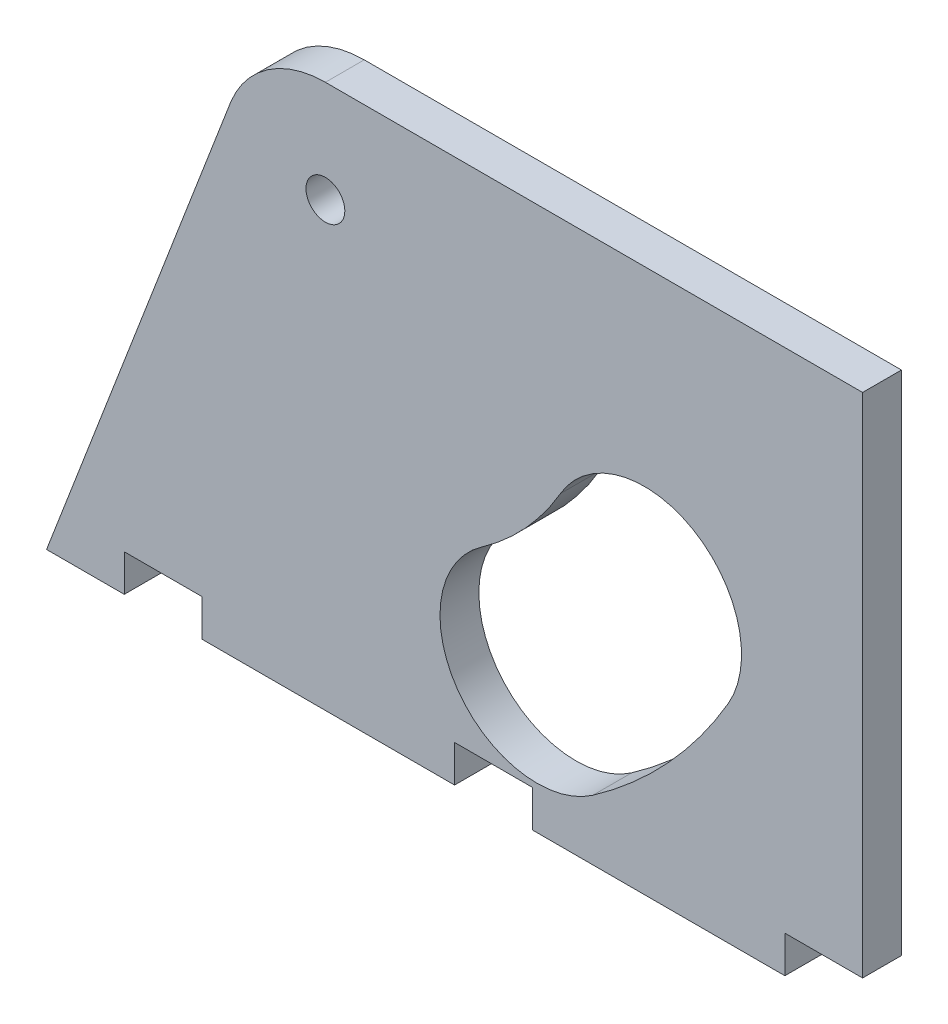
from build123d import *

# Parameters (mm, degrees)
SKETCH1_W           = 120
SKETCH1_H           = 100
BOSS_EXTRUDE1_DEPTH = 5
SKETCH2_R           = 2.5
CUT_EXTRUDE1_DEPTH  = 6
SKETCH3_W           = 120
SKETCH3_H           = 2
BOSS_EXTRUDE2_DEPTH = 20
CUT_EXTRUDE2_DEPTH  = 26
CUT_EXTRUDE3_DEPTH  = 26
SKETCH6_W           = 5
SKETCH6_H           = 30
BOSS_EXTRUDE3_DEPTH = 20
CUT_EXTRUDE4_DEPTH  = 106
SKETCH10_W          = 27.884556649
SKETCH10_H          = 70
CUT_EXTRUDE5_DEPTH  = 106
SKETCH11_W          = 20
SKETCH11_H          = 30
CUT_EXTRUDE6_DEPTH  = 106
SKETCH12_W          = 10
SKETCH12_H          = 4.75
CUT_EXTRUDE7_DEPTH  = 6


with BuildPart() as part:
    # Sketch1 → Boss-Extrude1 (new body)
    with BuildSketch(Plane.XY):
        with Locations((60, 50)):
            Rectangle(SKETCH1_W, SKETCH1_H)
    boss_extrude1 = extrude(amount=BOSS_EXTRUDE1_DEPTH)

    # Sketch2 → Cut-Extrude1 (cut, through all)
    with BuildSketch(Plane.XY.offset(5)):
        with Locations((50.878001036, 56.909722104)):
            Circle(SKETCH2_R)
        with BuildLine():
            ThreePointArc((85.292587217, 7.760599446), (95.03577446, 16.288409394), (102.722518982, 26.707967867))
            ThreePointArc((102.722518982, 26.707967867), (98.213609876, 43.800941239), (81.120636505, 39.292032133))
            ThreePointArc((81.120636505, 39.292032133), (76.6367022, 33.213956356), (70.953176308, 28.239400554))
            ThreePointArc((70.953176308, 28.239400554), (67.883481209, 10.830294546), (85.292587217, 7.760599446))
        make_face()
    cut_extrude1 = extrude(amount=-CUT_EXTRUDE1_DEPTH, mode=Mode.SUBTRACT)

    # Sketch3 → Boss-Extrude2 (add)
    with BuildSketch(Plane(origin=(0, 0, 0), x_dir=(-1, 0, 0), z_dir=(0, 0, -1))):
        with Locations((-60, 1)):
            Rectangle(SKETCH3_W, SKETCH3_H)
    boss_extrude2 = extrude(amount=BOSS_EXTRUDE2_DEPTH)

    # Sketch4 → Cut-Extrude2 (cut, through all)
    with BuildSketch(Plane.XY.offset(5)):
        with BuildLine():
            ThreePointArc((71.705399269, 35.987211382), (76.514173113, 43.433069144), (75.177144341, 52.195343835))
            ThreePointArc((75.177144341, 52.195343835), (71.771162127, 53.143650303), (70.822855659, 49.737668089))
            ThreePointArc((70.822855659, 49.737668089), (71.625072922, 44.480303275), (68.739808616, 40.012788618))
            ThreePointArc((68.739808616, 40.012788618), (68.209815325, 36.517204673), (71.705399269, 35.987211382))
        make_face()
    extrude(amount=-CUT_EXTRUDE2_DEPTH, mode=Mode.SUBTRACT)

    # Sketch5 → Cut-Extrude3 (cut, through all)
    with BuildSketch(Plane.XY.offset(5)):
        with BuildLine():
            Line((120, 70), (50.878001036, 70))
            ThreePointArc((50.878001036, 70), (43.464411706, 67.698330385), (38.657892056, 61.602728806))
            Line((38.657892056, 61.602728806), (15, 0))
            Line((15, 0), (0, 0))
            Line((0, 0), (0, 100))
            Line((0, 100), (120, 100))
            Line((120, 100), (120, 70))
        make_face()
    cut_extrude3 = extrude(amount=-CUT_EXTRUDE3_DEPTH, mode=Mode.SUBTRACT)

    # Sketch6 → Boss-Extrude3 (add, through all)
    with BuildSketch(Plane(origin=(0, 0, 0), x_dir=(-1, 0, 0), z_dir=(0, 0, -1))):
        with Locations((-117.5, 15)):
            Rectangle(SKETCH6_W, SKETCH6_H)
        with Locations((-32.5, 15)):
            Rectangle(SKETCH6_W, SKETCH6_H)
    boss_extrude3 = extrude(amount=BOSS_EXTRUDE3_DEPTH)

    # Sketch9 → Cut-Extrude4 (cut, through all)
    with BuildSketch(Plane(origin=(120, 0, 0), x_dir=(0, 0, -1), z_dir=(1, 0, 0))):
        Polygon((0, 30), (20, 0), (20, 30), align=None)
    cut_extrude4 = extrude(amount=-CUT_EXTRUDE4_DEPTH, mode=Mode.SUBTRACT)

    # Mirror1: Boss-Extrude1, Cut-Extrude1, Boss-Extrude2, Cut-Extrude3, Boss-Extrude3, Cut-Extrude4 across plane
    add(boss_extrude1.mirror(Plane(origin=(0, 0, 5), x_dir=(1, 0, 0), z_dir=(0, 0, -1))))
    add(cut_extrude1.mirror(Plane(origin=(0, 0, 5), x_dir=(1, 0, 0), z_dir=(0, 0, -1))), mode=Mode.SUBTRACT)
    add(boss_extrude2.mirror(Plane(origin=(0, 0, 5), x_dir=(1, 0, 0), z_dir=(0, 0, -1))))
    add(cut_extrude3.mirror(Plane(origin=(0, 0, 5), x_dir=(1, 0, 0), z_dir=(0, 0, -1))), mode=Mode.SUBTRACT)
    add(boss_extrude3.mirror(Plane(origin=(0, 0, 5), x_dir=(1, 0, 0), z_dir=(0, 0, -1))))
    add(cut_extrude4.mirror(Plane(origin=(0, 0, 5), x_dir=(1, 0, 0), z_dir=(0, 0, -1))), mode=Mode.SUBTRACT)

    # Sketch10 → Cut-Extrude5 (cut, through all)
    with BuildSketch(Plane(origin=(120, 0, 0), x_dir=(0, 0, -1), z_dir=(1, 0, 0))):
        with Locations((8.942278325, 35)):
            Rectangle(SKETCH10_W, SKETCH10_H)
    extrude(amount=-CUT_EXTRUDE5_DEPTH, mode=Mode.SUBTRACT)

    # Sketch11 → Cut-Extrude6 (cut, through all)
    with BuildSketch(Plane(origin=(120, 0, 0), x_dir=(0, 0, -1), z_dir=(1, 0, 0))):
        with Locations((-20, 15)):
            Rectangle(SKETCH11_W, SKETCH11_H)
    extrude(amount=-CUT_EXTRUDE6_DEPTH, mode=Mode.SUBTRACT)

    # Sketch12 → Cut-Extrude7 (cut, through all)
    with BuildSketch(Plane.XY.offset(10)):
        with Locations((115, 2.375)):
            Rectangle(SKETCH12_W, SKETCH12_H)
        with Locations((72.5, 2.375)):
            Rectangle(SKETCH12_W, SKETCH12_H)
        with Locations((30, 2.375)):
            Rectangle(SKETCH12_W, SKETCH12_H)
    extrude(amount=-CUT_EXTRUDE7_DEPTH, mode=Mode.SUBTRACT)


solid = part.part
